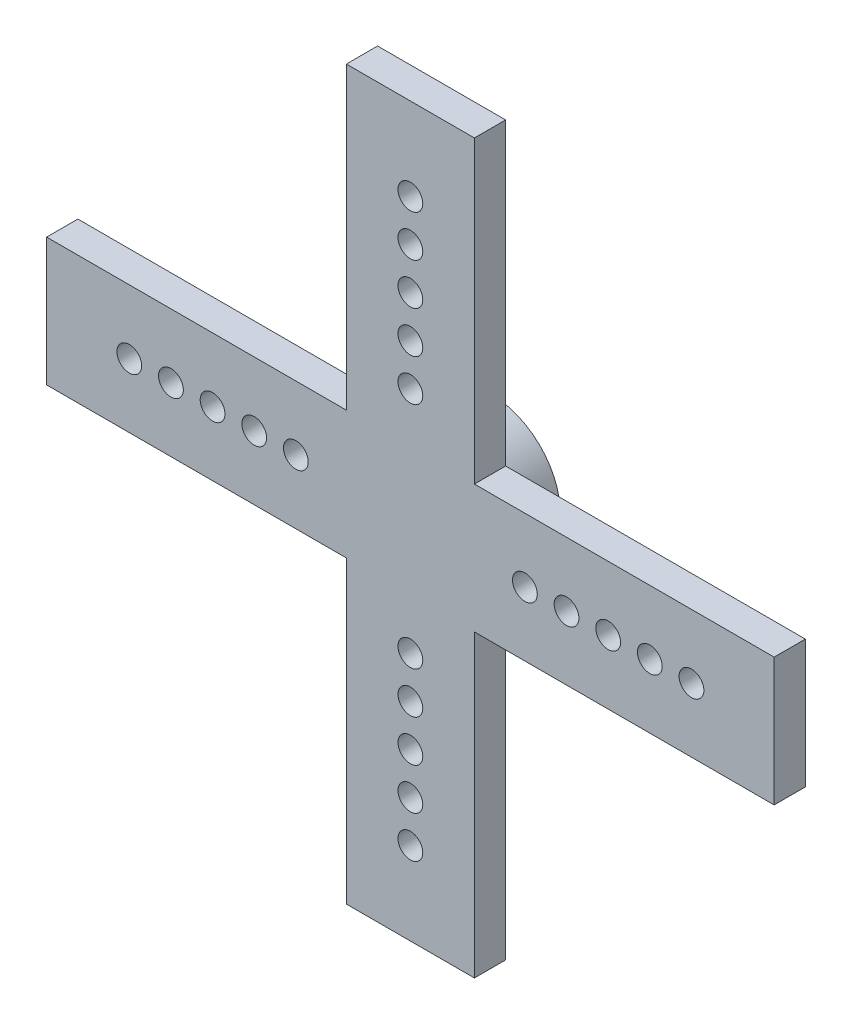
from build123d import *

# Parameters (mm, degrees)
SKETCH1_W         = 44.3738
SKETCH1_H         = 44.3738
EXTRUDE1_DEPTH    = 1.905
SKETCH2_R         = 4.2291
SKETCH2_R_2       = 2.9718
EXTRUDE2_DEPTH    = 3.0226
LPATTERN2_COUNT   = 5
LPATTERN2_PITCH   = 2.54
CIRPATTERN2_COUNT = 4
SKETCH6_W         = 18.282489336
SKETCH6_H         = 18.282489336
EXTRUDE3_DEPTH    = 5.9276
CIRPATTERN3_COUNT = 4


with BuildPart() as part:
    # Sketch1 → Extrude1 (new body)
    with BuildSketch(Plane.XY):
        Rectangle(SKETCH1_W, SKETCH1_H)
    extrude(amount=EXTRUDE1_DEPTH)

    # Sketch2 → Extrude2 (add)
    with BuildSketch(Plane(origin=(0, 0, 0), x_dir=(-1, 0, 0), z_dir=(0, 0, -1))):
        Circle(SKETCH2_R)
        Circle(SKETCH2_R_2, mode=Mode.SUBTRACT)
    extrude(amount=EXTRUDE2_DEPTH)

    # Sketch4 → #53 (0.0595) Diameter Hole1 (revolve, cut)
    with BuildSketch(Plane(origin=(6.985, 0, 1.905), x_dir=(0, -1, 0), z_dir=(1, 0, 0))):
        Polygon((0, 0), (0, 5.534040327), (0.75565, 5.08), (0.75565, 0), align=None)
    f_53_0_0595_diameter_hole1 = revolve(axis=Axis((6.985, 0, 8.255), (0, 0, -1)), mode=Mode.SUBTRACT)

    # LPattern2: #53 (0.0595) Diameter Hole1 ×5
    with Locations(*[(i * LPATTERN2_PITCH, 0, 0) for i in range(1, LPATTERN2_COUNT)]):
        add(f_53_0_0595_diameter_hole1, mode=Mode.SUBTRACT)

    # CirPattern2: #53 (0.0595) Diameter Hole1 ×4 about axis
    cirpattern2_axis = Axis((0, 0, 0), (0, 0, 1))
    for i in range(1, CIRPATTERN2_COUNT):
        add(f_53_0_0595_diameter_hole1.rotate(cirpattern2_axis, i * 360 / CIRPATTERN2_COUNT), mode=Mode.SUBTRACT)

    # CirPattern2 copy 1 sketch → CirPattern2 copy 1 (revolve, cut)
    with BuildSketch(Plane(origin=(0, 9.525, 1.905), x_dir=(1, 0, 0), z_dir=(0, 1, 0))):
        Polygon((0, 0), (0, 5.534040327), (0.75565, 5.08), (0.75565, 0), align=None)
    revolve(axis=Axis((0, 9.525, 8.255), (0, 0, -1)), mode=Mode.SUBTRACT)

    # CirPattern2 copy 2 sketch → CirPattern2 copy 2 (revolve, cut)
    with BuildSketch(Plane(origin=(-9.525, 0, 1.905), x_dir=(0, 1, 0), z_dir=(-1, 0, 0))):
        Polygon((0, 0), (0, 5.534040327), (0.75565, 5.08), (0.75565, 0), align=None)
    revolve(axis=Axis((-9.525, 0, 8.255), (0, 0, -1)), mode=Mode.SUBTRACT)

    # CirPattern2 copy 3 sketch → CirPattern2 copy 3 (revolve, cut)
    with BuildSketch(Plane(origin=(0, -9.525, 1.905), x_dir=(-1, 0, 0), z_dir=(0, -1, 0))):
        Polygon((0, 0), (0, 5.534040327), (0.75565, 5.08), (0.75565, 0), align=None)
    revolve(axis=Axis((0, -9.525, 8.255), (0, 0, -1)), mode=Mode.SUBTRACT)

    # CirPattern2 copy 4 sketch → CirPattern2 copy 4 (revolve, cut)
    with BuildSketch(Plane(origin=(0, 12.065, 1.905), x_dir=(1, 0, 0), z_dir=(0, 1, 0))):
        Polygon((0, 0), (0, 5.534040327), (0.75565, 5.08), (0.75565, 0), align=None)
    revolve(axis=Axis((0, 12.065, 8.255), (0, 0, -1)), mode=Mode.SUBTRACT)

    # CirPattern2 copy 5 sketch → CirPattern2 copy 5 (revolve, cut)
    with BuildSketch(Plane(origin=(-12.065, 0, 1.905), x_dir=(0, 1, 0), z_dir=(-1, 0, 0))):
        Polygon((0, 0), (0, 5.534040327), (0.75565, 5.08), (0.75565, 0), align=None)
    revolve(axis=Axis((-12.065, 0, 8.255), (0, 0, -1)), mode=Mode.SUBTRACT)

    # CirPattern2 copy 6 sketch → CirPattern2 copy 6 (revolve, cut)
    with BuildSketch(Plane(origin=(0, -12.065, 1.905), x_dir=(-1, 0, 0), z_dir=(0, -1, 0))):
        Polygon((0, 0), (0, 5.534040327), (0.75565, 5.08), (0.75565, 0), align=None)
    revolve(axis=Axis((0, -12.065, 8.255), (0, 0, -1)), mode=Mode.SUBTRACT)

    # CirPattern2 copy 7 sketch → CirPattern2 copy 7 (revolve, cut)
    with BuildSketch(Plane(origin=(0, 14.605, 1.905), x_dir=(1, 0, 0), z_dir=(0, 1, 0))):
        Polygon((0, 0), (0, 5.534040327), (0.75565, 5.08), (0.75565, 0), align=None)
    revolve(axis=Axis((0, 14.605, 8.255), (0, 0, -1)), mode=Mode.SUBTRACT)

    # CirPattern2 copy 8 sketch → CirPattern2 copy 8 (revolve, cut)
    with BuildSketch(Plane(origin=(-14.605, 0, 1.905), x_dir=(0, 1, 0), z_dir=(-1, 0, 0))):
        Polygon((0, 0), (0, 5.534040327), (0.75565, 5.08), (0.75565, 0), align=None)
    revolve(axis=Axis((-14.605, 0, 8.255), (0, 0, -1)), mode=Mode.SUBTRACT)

    # CirPattern2 copy 9 sketch → CirPattern2 copy 9 (revolve, cut)
    with BuildSketch(Plane(origin=(0, -14.605, 1.905), x_dir=(-1, 0, 0), z_dir=(0, -1, 0))):
        Polygon((0, 0), (0, 5.534040327), (0.75565, 5.08), (0.75565, 0), align=None)
    revolve(axis=Axis((0, -14.605, 8.255), (0, 0, -1)), mode=Mode.SUBTRACT)

    # CirPattern2 copy 10 sketch → CirPattern2 copy 10 (revolve, cut)
    with BuildSketch(Plane(origin=(0, 17.145, 1.905), x_dir=(1, 0, 0), z_dir=(0, 1, 0))):
        Polygon((0, 0), (0, 5.534040327), (0.75565, 5.08), (0.75565, 0), align=None)
    revolve(axis=Axis((0, 17.145, 8.255), (0, 0, -1)), mode=Mode.SUBTRACT)

    # CirPattern2 copy 11 sketch → CirPattern2 copy 11 (revolve, cut)
    with BuildSketch(Plane(origin=(-17.145, 0, 1.905), x_dir=(0, 1, 0), z_dir=(-1, 0, 0))):
        Polygon((0, 0), (0, 5.534040327), (0.75565, 5.08), (0.75565, 0), align=None)
    revolve(axis=Axis((-17.145, 0, 8.255), (0, 0, -1)), mode=Mode.SUBTRACT)

    # CirPattern2 copy 12 sketch → CirPattern2 copy 12 (revolve, cut)
    with BuildSketch(Plane(origin=(0, -17.145, 1.905), x_dir=(-1, 0, 0), z_dir=(0, -1, 0))):
        Polygon((0, 0), (0, 5.534040327), (0.75565, 5.08), (0.75565, 0), align=None)
    revolve(axis=Axis((0, -17.145, 8.255), (0, 0, -1)), mode=Mode.SUBTRACT)

    # Sketch6 → Extrude3 (cut, through all)
    with BuildSketch(Plane.XY.offset(1.905)):
        with Locations((-13.045655332, 13.045655332)):
            Rectangle(SKETCH6_W, SKETCH6_H)
    extrude3 = extrude(amount=-EXTRUDE3_DEPTH, mode=Mode.SUBTRACT)

    # CirPattern3: Extrude3 ×4 about axis
    cirpattern3_axis = Axis((0, 0, 0), (0, 0, 1))
    for i in range(1, CIRPATTERN3_COUNT):
        add(extrude3.rotate(cirpattern3_axis, i * 360 / CIRPATTERN3_COUNT), mode=Mode.SUBTRACT)


solid = part.part
